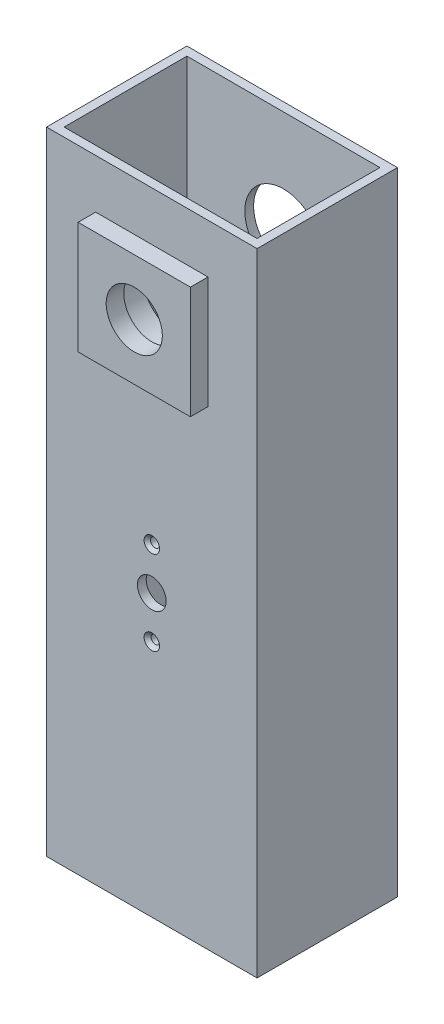
from build123d import *

# Parameters (mm, degrees)
SKETCH1_W                                       = 60
SKETCH1_H                                       = 40
SKETCH1_W_2                                     = 55
SKETCH1_H_2                                     = 35
BOSS_EXTRUDE1_DEPTH                             = 200
CUT_EXTRUDE1_DEPTH                              = 74.376629
SKETCH3_W                                       = 40
SKETCH3_H                                       = 40
SKETCH3_R                                       = 11
BOSS_EXTRUDE2_DEPTH                             = 4.5
SKETCH4_R                                       = 4
CUT_EXTRUDE2_DEPTH                              = 258.5
CUT_EXTRUDE3_DEPTH                              = 73
SKETCH6_R                                       = 22
CUT_EXTRUDE4_DEPTH                              = 6
SKETCH7_R                                       = 1
CUT_EXTRUDE5_DEPTH                              = 6
CSK_FOR_M2_FLAT_HEAD_MACHINE_SCREW1_D           = 2.6
CSK_FOR_M2_FLAT_HEAD_MACHINE_SCREW1_DEPTH       = 15
CSK_FOR_M2_FLAT_HEAD_MACHINE_SCREW1_CSINK_D     = 4.4
CSK_FOR_M2_FLAT_HEAD_MACHINE_SCREW1_CSINK_ANGLE = 90
CSK_FOR_M2_FLAT_HEAD_MACHINE_SCREW1_TIP         = 0.781119
SKETCH11_R                                      = 4.1
CUT_EXTRUDE6_DEPTH                              = 6
SKETCH12_R                                      = 1.289857
SKETCH12_R_2                                    = 0.80802
CUT_EXTRUDE7_DEPTH                              = 6
CSK_FOR_M2_FLAT_HEAD_MACHINE_SCREW3_D           = 2.4
CSK_FOR_M2_FLAT_HEAD_MACHINE_SCREW3_DEPTH       = 15
CSK_FOR_M2_FLAT_HEAD_MACHINE_SCREW3_CSINK_D     = 4.4
CSK_FOR_M2_FLAT_HEAD_MACHINE_SCREW3_CSINK_ANGLE = 90
CSK_FOR_M2_FLAT_HEAD_MACHINE_SCREW3_TIP         = 0.721033
SKETCH17_W                                      = 6.292961
SKETCH17_H                                      = 8.782939
SKETCH17_W_2                                    = 8.588554
SKETCH17_H_2                                    = 10.208281
BOSS_EXTRUDE3_DEPTH                             = 2.5
SKETCH18_W                                      = 40
SKETCH18_H                                      = 40
SKETCH18_R                                      = 11
BOSS_EXTRUDE4_DEPTH                             = 1
SKETCH19_W                                      = 32
SKETCH19_H                                      = 32
SKETCH19_R                                      = 11
BOSS_EXTRUDE5_DEPTH                             = 5
SKETCH20_R                                      = 11
SKETCH20_R_2                                    = 8
BOSS_EXTRUDE6_DEPTH                             = 5


with BuildPart() as part:
    # Sketch1 → Boss-Extrude1 (new body)
    with BuildSketch(Plane(origin=(0, 0, 0), x_dir=(1, 0, 0), z_dir=(0, 1, 0))):
        with Locations((-30, -20)):
            Rectangle(SKETCH1_W, SKETCH1_H)
        with Locations((-30, -20)):
            Rectangle(SKETCH1_W_2, SKETCH1_H_2, mode=Mode.SUBTRACT)
    extrude(amount=BOSS_EXTRUDE1_DEPTH)

    # Sketch2 → Cut-Extrude1 (cut)
    with BuildSketch(Plane(origin=(0, 0, 0), x_dir=(-1, 0, 0), z_dir=(0, 0, -1))):
        with BuildLine():
            ThreePointArc((41, 170), (34.209518, 180.162675), (22.221825, 177.778175))
            Line((22.221825, 177.778175), (37.778175, 162.221825))
            ThreePointArc((37.778175, 162.221825), (40.162675, 165.790482), (41, 170))
        make_face()
        with BuildLine():
            Line((37.778175, 162.221825), (22.221825, 177.778175))
            ThreePointArc((22.221825, 177.778175), (22.221825, 162.221825), (37.778175, 162.221825))
        make_face()
    extrude(amount=-CUT_EXTRUDE1_DEPTH, mode=Mode.SUBTRACT)

    # Sketch3 → Boss-Extrude2 (add)
    with BuildSketch(Plane(origin=(0, 0, 37.5), x_dir=(-1, 0, 0), z_dir=(0, 0, -1))):
        with Locations((30, 170)):
            Rectangle(SKETCH3_W, SKETCH3_H)
        with Locations((30, 170)):
            Circle(SKETCH3_R, mode=Mode.SUBTRACT)
    extrude(amount=BOSS_EXTRUDE2_DEPTH)

    # Sketch4 → Cut-Extrude2 (cut)
    with BuildSketch(Plane.XY.offset(40)):
        with Locations((-30, 100)):
            Circle(SKETCH4_R)
    extrude(amount=-CUT_EXTRUDE2_DEPTH, mode=Mode.SUBTRACT)

    # Sketch5 → Cut-Extrude3 (cut)
    with BuildSketch(Plane(origin=(0, 0, 0), x_dir=(-1, 0, 0), z_dir=(0, 0, -1))):
        Polygon((60, 20), (30, 20), (0, 20), (0, 0), (60, 0), align=None)
    extrude(amount=-CUT_EXTRUDE3_DEPTH, mode=Mode.SUBTRACT)

    # Sketch6 → Cut-Extrude4 (cut)
    with BuildSketch(Plane(origin=(0, 0, 0), x_dir=(-1, 0, 0), z_dir=(0, 0, -1))):
        with Locations((30, 100)):
            Circle(SKETCH6_R)
    extrude(amount=-CUT_EXTRUDE4_DEPTH, mode=Mode.SUBTRACT)

    # Sketch7 → Cut-Extrude5 (cut)
    with BuildSketch(Plane.XY.offset(40)):
        with Locations((-42, 100)):
            Circle(SKETCH7_R)
        with Locations((-18, 100)):
            Circle(SKETCH7_R)
    extrude(amount=-CUT_EXTRUDE5_DEPTH, mode=Mode.SUBTRACT)

    # CSK for M2 Flat Head Machine Screw1
    with Locations(Plane.XY.offset(40)):
        with Locations((-42, 100), (-18, 100)):
            CounterSinkHole(CSK_FOR_M2_FLAT_HEAD_MACHINE_SCREW1_D / 2, CSK_FOR_M2_FLAT_HEAD_MACHINE_SCREW1_CSINK_D / 2, depth=CSK_FOR_M2_FLAT_HEAD_MACHINE_SCREW1_DEPTH, counter_sink_angle=CSK_FOR_M2_FLAT_HEAD_MACHINE_SCREW1_CSINK_ANGLE)
            with Locations((0, 0, -(CSK_FOR_M2_FLAT_HEAD_MACHINE_SCREW1_DEPTH + CSK_FOR_M2_FLAT_HEAD_MACHINE_SCREW1_TIP / 2))):  # 118° drill point
                Cone(0, CSK_FOR_M2_FLAT_HEAD_MACHINE_SCREW1_D / 2, CSK_FOR_M2_FLAT_HEAD_MACHINE_SCREW1_TIP, mode=Mode.SUBTRACT)

    # Sketch11 → Cut-Extrude6 (cut)
    with BuildSketch(Plane.XY.offset(40)):
        with Locations((-30, 100)):
            Circle(SKETCH11_R)
    extrude(amount=-CUT_EXTRUDE6_DEPTH, mode=Mode.SUBTRACT)

    # Sketch12 → Cut-Extrude7 (cut)
    with BuildSketch(Plane.XY.offset(40)):
        with Locations((-30, 112)):
            Circle(SKETCH12_R)
        with Locations((-30, 88)):
            Circle(SKETCH12_R_2)
    extrude(amount=-CUT_EXTRUDE7_DEPTH, mode=Mode.SUBTRACT)

    # CSK for M2 Flat Head Machine Screw3
    with Locations(Plane.XY.offset(40)):
        with Locations((-30, 112), (-30, 88)):
            CounterSinkHole(CSK_FOR_M2_FLAT_HEAD_MACHINE_SCREW3_D / 2, CSK_FOR_M2_FLAT_HEAD_MACHINE_SCREW3_CSINK_D / 2, depth=CSK_FOR_M2_FLAT_HEAD_MACHINE_SCREW3_DEPTH, counter_sink_angle=CSK_FOR_M2_FLAT_HEAD_MACHINE_SCREW3_CSINK_ANGLE)
            with Locations((0, 0, -(CSK_FOR_M2_FLAT_HEAD_MACHINE_SCREW3_DEPTH + CSK_FOR_M2_FLAT_HEAD_MACHINE_SCREW3_TIP / 2))):  # 118° drill point
                Cone(0, CSK_FOR_M2_FLAT_HEAD_MACHINE_SCREW3_D / 2, CSK_FOR_M2_FLAT_HEAD_MACHINE_SCREW3_TIP, mode=Mode.SUBTRACT)

    # Sketch17 → Boss-Extrude3 (add)
    with BuildSketch(Plane.XY.offset(40)):
        with Locations((-18.162519, 99.731353)):
            Rectangle(SKETCH17_W, SKETCH17_H)
        with Locations((-41.340858, 100.800418)):
            Rectangle(SKETCH17_W_2, SKETCH17_H_2)
    extrude(amount=-BOSS_EXTRUDE3_DEPTH)

    # Sketch18 → Boss-Extrude4 (add)
    with BuildSketch(Plane(origin=(0, 0, 33), x_dir=(-1, 0, 0), z_dir=(0, 0, -1))):
        with Locations((30, 170)):
            Rectangle(SKETCH18_W, SKETCH18_H)
        with Locations((30, 170)):
            Circle(SKETCH18_R, mode=Mode.SUBTRACT)
    extrude(amount=BOSS_EXTRUDE4_DEPTH)

    # Sketch19 → Boss-Extrude5 (add)
    with BuildSketch(Plane.XY.offset(40)):
        with Locations((-30, 170)):
            Rectangle(SKETCH19_W, SKETCH19_H)
        with Locations((-30, 170)):
            Circle(SKETCH19_R, mode=Mode.SUBTRACT)
    extrude(amount=BOSS_EXTRUDE5_DEPTH)

    # Sketch20 → Boss-Extrude6 (add)
    with BuildSketch(Plane.XY.offset(45)):
        with Locations((-30, 170)):
            Circle(SKETCH20_R)
        with Locations((-30, 170)):
            Circle(SKETCH20_R_2, mode=Mode.SUBTRACT)
    extrude(amount=-BOSS_EXTRUDE6_DEPTH)


solid = part.part
